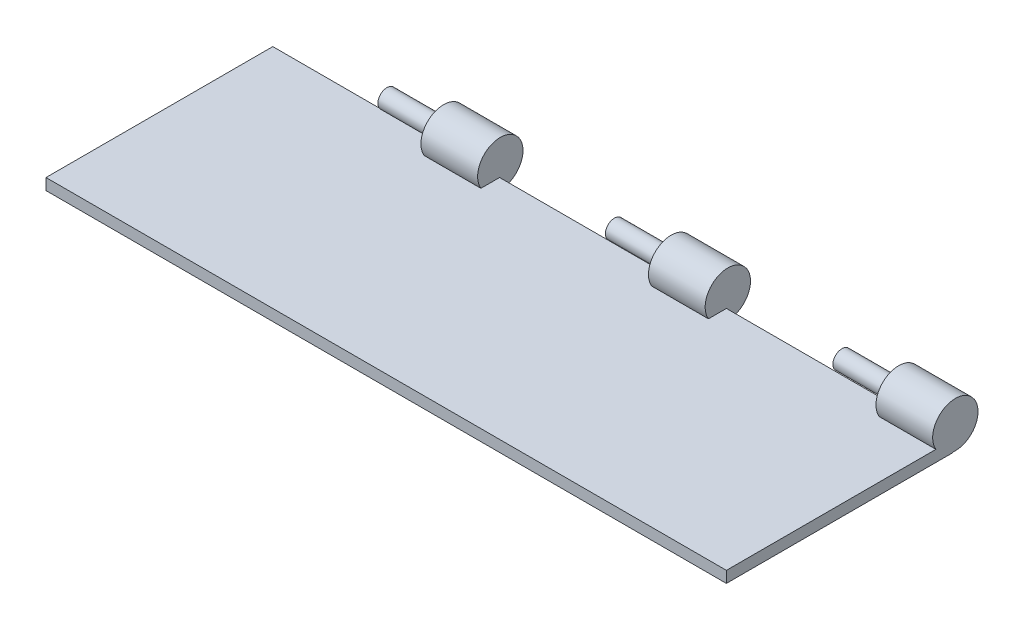
from build123d import *

# Parameters (mm, degrees)
SKETCH1_W           = 300
SKETCH1_H           = 100
BOSS_EXTRUDE1_DEPTH = 5
SKETCH7_R           = 10
BOSS_EXTRUDE5_DEPTH = 25
SKETCH10_R          = 4
BOSS_EXTRUDE6_DEPTH = 50
LPATTERN1_COUNT     = 3
LPATTERN1_PITCH     = 100


with BuildPart() as part:
    # Sketch1 → Boss-Extrude1 (new body)
    with BuildSketch(Plane(origin=(0, 0, 0), x_dir=(1, 0, 0), z_dir=(0, 1, 0))):
        Rectangle(SKETCH1_W, SKETCH1_H)
    extrude(amount=BOSS_EXTRUDE1_DEPTH)

    # Sketch7 → Boss-Extrude5 (add)
    with BuildSketch(Plane(origin=(150, 0, 0), x_dir=(0, 0, -1), z_dir=(1, 0, 0))):
        with Locations((50.954154719, 10.172311349)):
            Circle(SKETCH7_R)
    boss_extrude5 = extrude(amount=-BOSS_EXTRUDE5_DEPTH)

    # Sketch10 → Boss-Extrude6 (add)
    with BuildSketch(Plane(origin=(150, 0, 0), x_dir=(0, 0, -1), z_dir=(1, 0, 0))):
        with Locations((50.954154719, 10.172311349)):
            Circle(SKETCH10_R)
    boss_extrude6 = extrude(amount=-BOSS_EXTRUDE6_DEPTH)

    # LPattern1: Boss-Extrude5, Boss-Extrude6 ×3
    with Locations(*[Vector(-0.999994942, 0, 0.0031805) * (i * LPATTERN1_PITCH) for i in range(1, LPATTERN1_COUNT)]):
        add(boss_extrude5)
        add(boss_extrude6)


solid = part.part
